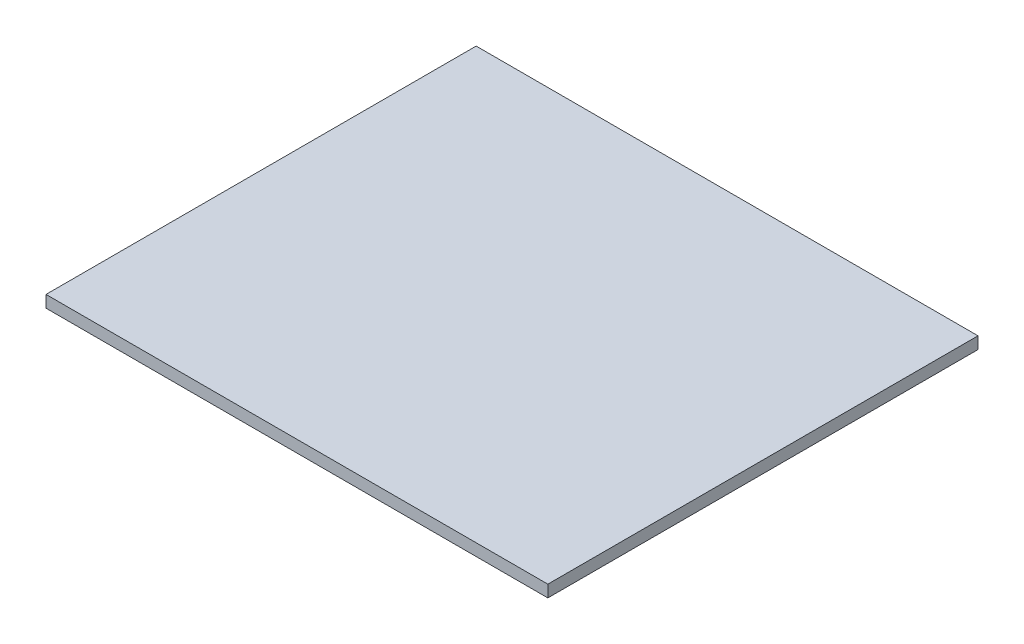
from build123d import *

# Parameters (mm, degrees)
SKETCH1_W           = 266.7
SKETCH1_H           = 228.6
BOSS_EXTRUDE1_DEPTH = 3.175


with BuildPart() as part:
    # Sketch1 → Boss-Extrude1 (new body, symmetric)
    with BuildSketch(Plane(origin=(0, 0, 0), x_dir=(1, 0, 0), z_dir=(0, 1, 0))):
        Rectangle(SKETCH1_W, SKETCH1_H)
    extrude(amount=BOSS_EXTRUDE1_DEPTH, both=True)


solid = part.part
